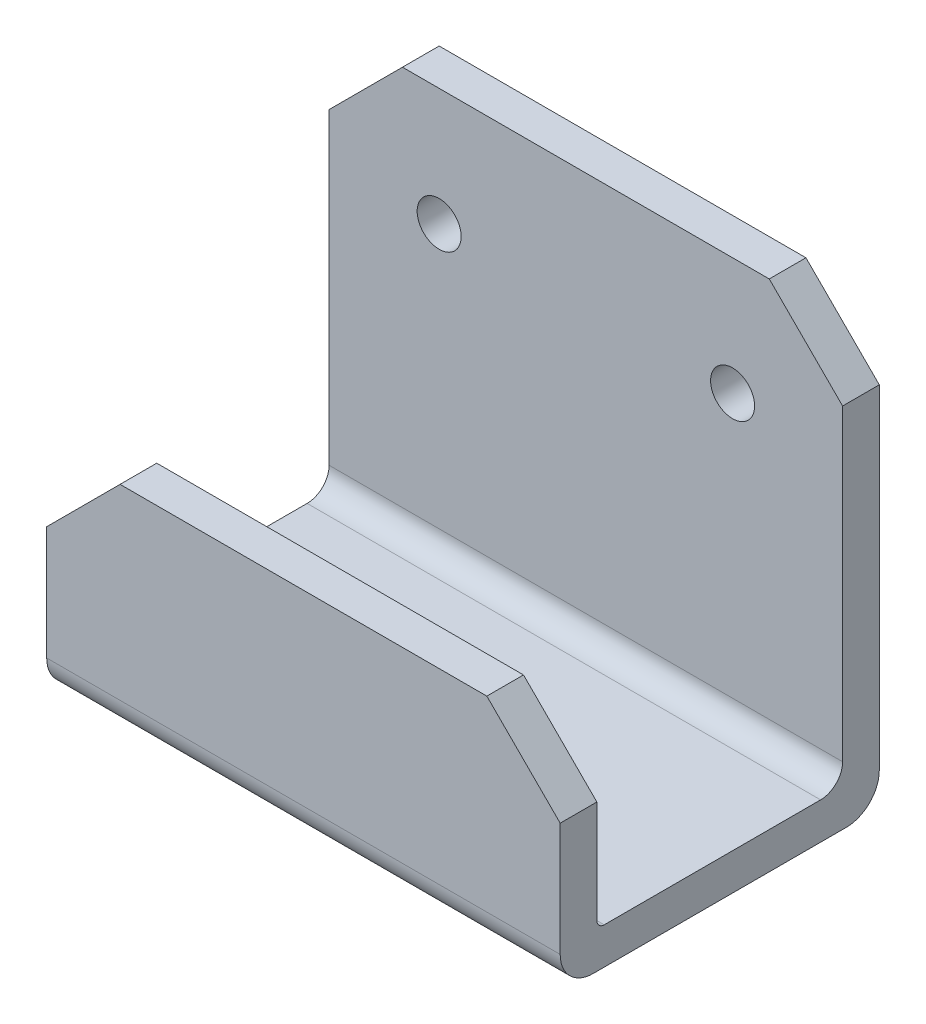
from build123d import *

# Parameters (mm, degrees)
BOSS_EXTRUDE1_DEPTH      = 35
BOSS_EXTRUDE1_DEPTH_BACK = 35
CHAMFER1_SIZE            = 10
SKETCH2_R                = 3
CUT_EXTRUDE1_DEPTH       = 35
FILLET1_R                = 3
FILLET2_R                = 4.5
FILLET3_R                = 1


with BuildPart() as part:
    # Sketch1 → Boss-Extrude1 (new, two sides: drawn at the far end of the back side and taken through both)
    with BuildSketch(Plane(origin=(0, 0, 0), x_dir=(0, 0, -1), z_dir=(1, 0, 0)).offset(-BOSS_EXTRUDE1_DEPTH_BACK)):
        Polygon((-21.75, 10), (-21.75, -20), (21.75, -20), (21.75, 40), (16.75, 40), (16.75, -15), (-16.75, -15), (-16.75, 10), align=None)
    extrude(amount=BOSS_EXTRUDE1_DEPTH + BOSS_EXTRUDE1_DEPTH_BACK)

    # Chamfer1
    chamfer1_edges = [part.edges().sort_by_distance(p)[0] for p in [
        (-35, 40, -19.25),
        (35, 40, -19.25),
        (35, 10, 19.25),
        (-35, 10, 19.25),
    ]]
    chamfer(chamfer1_edges, length=CHAMFER1_SIZE)

    # Sketch2 → Cut-Extrude1 (cut)
    with BuildSketch(Plane.XY.offset(-16.75)):
        with Locations((-20, 24)):
            Circle(SKETCH2_R)
        with Locations((20, 24)):
            Circle(SKETCH2_R)
    extrude(amount=-CUT_EXTRUDE1_DEPTH, mode=Mode.SUBTRACT)

    # Fillet1
    fillet1_edges = [part.edges().sort_by_distance(p)[0] for p in [
        (0, -15, -16.75),
    ]]
    fillet(fillet1_edges, radius=FILLET1_R)

    # Fillet2
    fillet2_edges = [part.edges().sort_by_distance(p)[0] for p in [
        (0, -20, 21.75),
        (0, -20, -21.75),
    ]]
    fillet(fillet2_edges, radius=FILLET2_R)

    # Fillet3
    fillet3_edges = [part.edges().sort_by_distance(p)[0] for p in [
        (0, -15, 16.75),
    ]]
    fillet(fillet3_edges, radius=FILLET3_R)


solid = part.part
